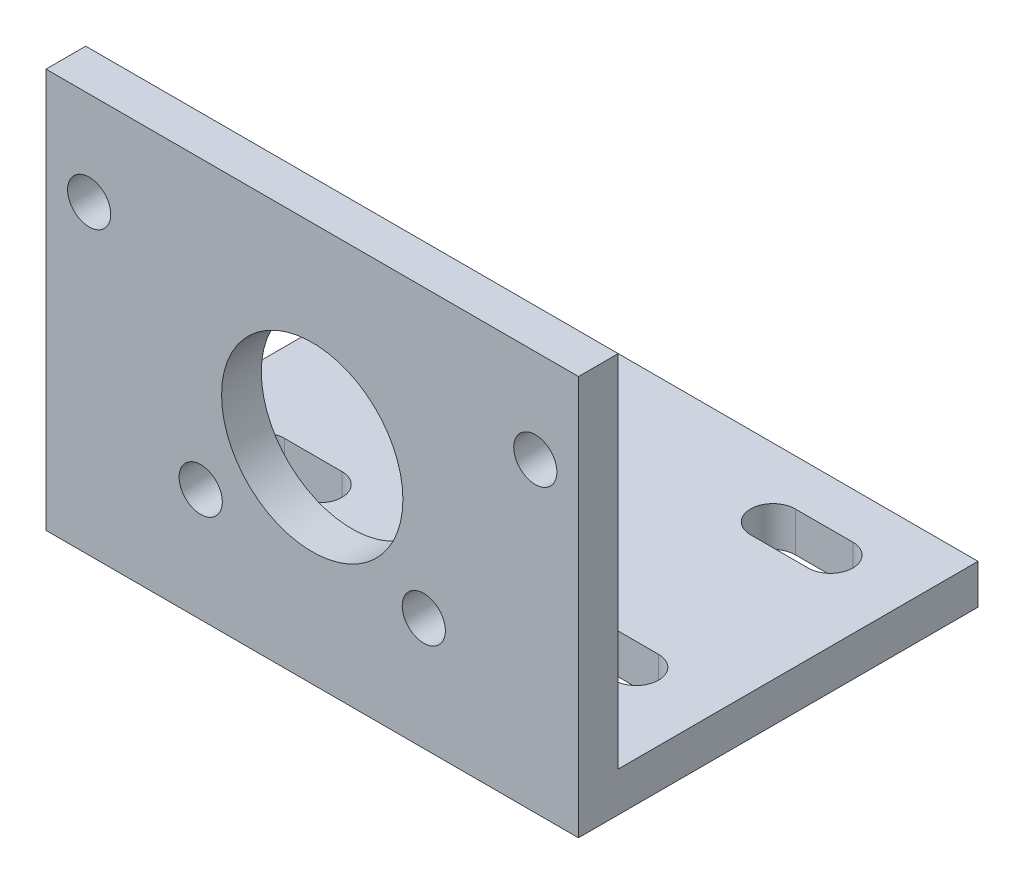
from build123d import *

# Parameters (mm, degrees)
BOSS_EXTRUDE1_DEPTH          = 18.5
SKETCH2_R                    = 6.3
CUT_EXTRUDE1_DEPTH           = 3.76
F_3_0_3_DIAMETER_HOLE1_D     = 3
F_3_0_3_DIAMETER_HOLE1_DEPTH = 10
F_3_0_3_DIAMETER_HOLE1_TIP   = 0.901290929
CUT_EXTRUDE2_DEPTH           = 3.76


with BuildPart() as part:
    # Sketch1 → Boss-Extrude1 (new body, symmetric)
    with BuildSketch(Plane(origin=(0, 0, 0), x_dir=(0, 0, -1), z_dir=(1, 0, 0))):
        Polygon((0, 0), (0, 27.76), (2.76, 27.76), (2.76, 2.76), (27.76, 2.76), (27.76, 0), align=None)
    extrude(amount=BOSS_EXTRUDE1_DEPTH, both=True)

    # Sketch2 → Cut-Extrude1 (cut, through all)
    with BuildSketch(Plane(origin=(0, 0, -2.76), x_dir=(-1, 0, 0), z_dir=(0, 0, -1))):
        with Locations((0, 14.26)):
            Circle(SKETCH2_R)
    extrude(amount=-CUT_EXTRUDE1_DEPTH, mode=Mode.SUBTRACT)

    # Ø3.0 (3) Diameter Hole1
    with Locations(Plane(origin=(0, 0, -2.76), x_dir=(-1, 0, 0), z_dir=(0, 0, -1))):
        with Locations((15.5, 21.26), (7.75, 7.836606241), (-7.75, 7.836606241), (-15.5, 21.26)):
            Hole(F_3_0_3_DIAMETER_HOLE1_D / 2, depth=F_3_0_3_DIAMETER_HOLE1_DEPTH)
            with Locations((0, 0, -(F_3_0_3_DIAMETER_HOLE1_DEPTH + F_3_0_3_DIAMETER_HOLE1_TIP / 2))):  # 118° drill point
                Cone(0, F_3_0_3_DIAMETER_HOLE1_D / 2, F_3_0_3_DIAMETER_HOLE1_TIP, mode=Mode.SUBTRACT)

    # Sketch5 → Cut-Extrude2 (cut, through all)
    with BuildSketch(Plane(origin=(0, 2.76, 0), x_dir=(1, 0, 0), z_dir=(0, 1, 0))):
        with BuildLine():
            Line((-13, 24.565), (-9, 24.565))
            ThreePointArc((-9, 24.565), (-7.445, 23.01), (-9, 21.455))
            Line((-9, 21.455), (-13, 21.455))
            ThreePointArc((-13, 21.455), (-14.555, 23.01), (-13, 24.565))
        make_face()
        with BuildLine():
            Line((-13, 11.065), (-9, 11.065))
            ThreePointArc((-9, 11.065), (-7.445, 9.51), (-9, 7.955))
            Line((-9, 7.955), (-13, 7.955))
            ThreePointArc((-13, 7.955), (-14.555, 9.51), (-13, 11.065))
        make_face()
        with BuildLine():
            Line((9, 11.065), (13, 11.065))
            ThreePointArc((13, 11.065), (14.555, 9.51), (13, 7.955))
            Line((13, 7.955), (9, 7.955))
            ThreePointArc((9, 7.955), (7.445, 9.51), (9, 11.065))
        make_face()
        with BuildLine():
            Line((9, 24.565), (13, 24.565))
            ThreePointArc((13, 24.565), (14.555, 23.01), (13, 21.455))
            Line((13, 21.455), (9, 21.455))
            ThreePointArc((9, 21.455), (7.445, 23.01), (9, 24.565))
        make_face()
    extrude(amount=-CUT_EXTRUDE2_DEPTH, mode=Mode.SUBTRACT)


solid = part.part
